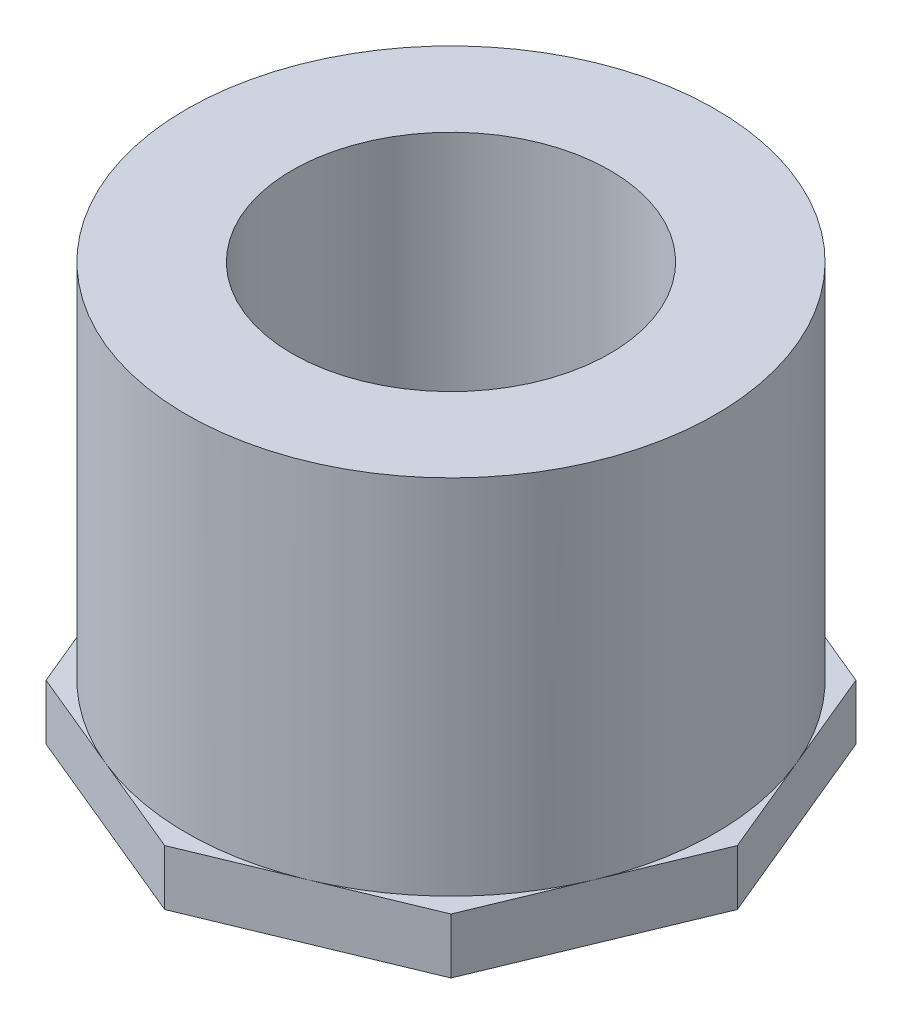
from build123d import *

# Parameters (mm, degrees)
SKETCH1_W           = 17.78
SKETCH1_H           = 38.1
SKETCH2_R           = 6.35
BOSS_EXTRUDE1_DEPTH = 5.0546


with BuildPart() as part:
    # Sketch1 → Revolve1 (revolve)
    with BuildSketch(Plane.XY):
        with Locations((-15.24, 19.05)):
            Rectangle(SKETCH1_W, SKETCH1_H)
    revolve(axis=Axis((0, 0, 0), (0, -1, 0)))

    # Sketch2 → Boss-Extrude1 (add)
    with BuildSketch(Plane.XZ):
        Polygon((0, 26.118123793), (-18.468302446, 18.468302446), (-26.118123793, 0), (-18.468302446, -18.468302446), (0, -26.118123793), (18.468302446, -18.468302446), (26.118123793, 0), (18.468302446, 18.468302446), align=None)
        Circle(SKETCH2_R, mode=Mode.SUBTRACT)
    extrude(amount=-BOSS_EXTRUDE1_DEPTH)

    # Sketch4 → 1 NPT Tapped Hole1 (revolve, cut)
    with BuildSketch(Plane(origin=(0, 0, 0), x_dir=(0, 0, -1), z_dir=(1, 0, 0))):
        Polygon((0, 0), (0, 38.1), (14.4907, 38.1), (14.4907, 16.78686), (15.227979931, 16.78686), (15.730601, 0), align=None)
    revolve(axis=Axis((0, -6.35, 0), (0, 1, 0)), mode=Mode.SUBTRACT)


solid = part.part
